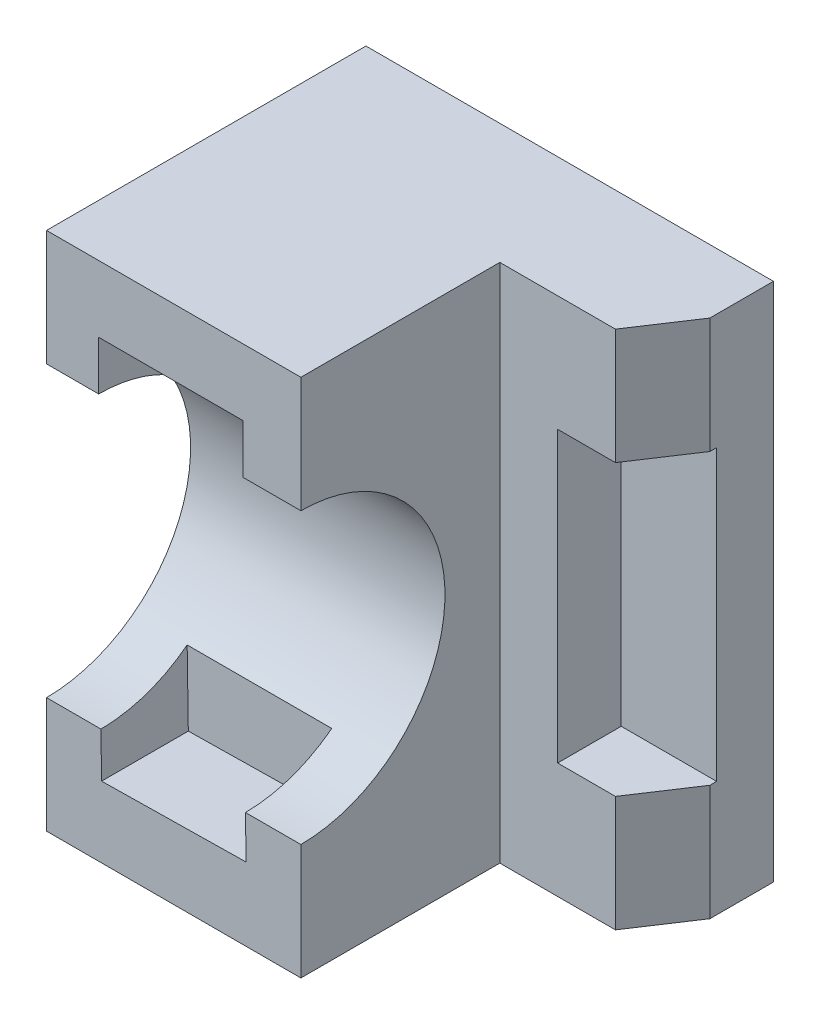
from build123d import *

# Parameters (mm, degrees)
SKETCH2_W               = 70.5
SKETCH2_H               = 90
BOSS_EXTRUDE1_DEPTH     = 55.25
CUT_EXTRUDE1_DEPTH      = 91
SKETCH4_R               = 25
CUT_EXTRUDE2_DEPTH      = 45
SKETCH6_W               = 16.5
SKETCH6_H               = 50
CUT_EXTRUDE3_DEPTH      = 35.414718703
CUT_EXTRUDE3_DEPTH_BACK = 11
SKETCH7_W               = 25
SKETCH7_H               = 15
CUT_EXTRUDE4_DEPTH      = 15


with BuildPart() as part:
    # Sketch2 → Boss-Extrude1 (new body)
    with BuildSketch(Plane.XY):
        Rectangle(SKETCH2_W, SKETCH2_H)
    extrude(amount=BOSS_EXTRUDE1_DEPTH)

    # Sketch3 → Cut-Extrude1 (cut, through all)
    with BuildSketch(Plane.XZ.offset(45)):
        Polygon((28.75, 20.835281297), (35.25, 11), (35.25, 55.25), (8.75, 55.25), (8.75, 20.835281297), align=None)
    extrude(amount=-CUT_EXTRUDE1_DEPTH, mode=Mode.SUBTRACT)

    # Sketch4 → Cut-Extrude2 (cut, through all)
    with BuildSketch(Plane(origin=(8.75, 0, 0), x_dir=(0, 0, -1), z_dir=(1, 0, 0))):
        with Locations((-55.327535333, 0)):
            Circle(SKETCH4_R)
    extrude(amount=-CUT_EXTRUDE2_DEPTH, mode=Mode.SUBTRACT)

    # Sketch6 → Cut-Extrude3 (cut, two sides)
    with BuildSketch(Plane.XY.offset(20.835281297)) as cut_extrude3_sk:
        with Locations((27, 0)):
            Rectangle(SKETCH6_W, SKETCH6_H)
    extrude(amount=CUT_EXTRUDE3_DEPTH, mode=Mode.SUBTRACT)
    extrude(cut_extrude3_sk.sketch, amount=-CUT_EXTRUDE3_DEPTH_BACK, mode=Mode.SUBTRACT)

    # Sketch7 → Cut-Extrude4 (cut)
    with BuildSketch(Plane.XY.offset(55.25)):
        with Locations((-13.733691731, 26)):
            Rectangle(SKETCH7_W, SKETCH7_H)
        Polygon((-25.955312552, -17.750715844), (-0.958260941, -17.366774787), (-0.727896306, -32.365005754), (-25.724947918, -32.748946811), align=None)
    extrude(amount=-CUT_EXTRUDE4_DEPTH, mode=Mode.SUBTRACT)


solid = part.part
